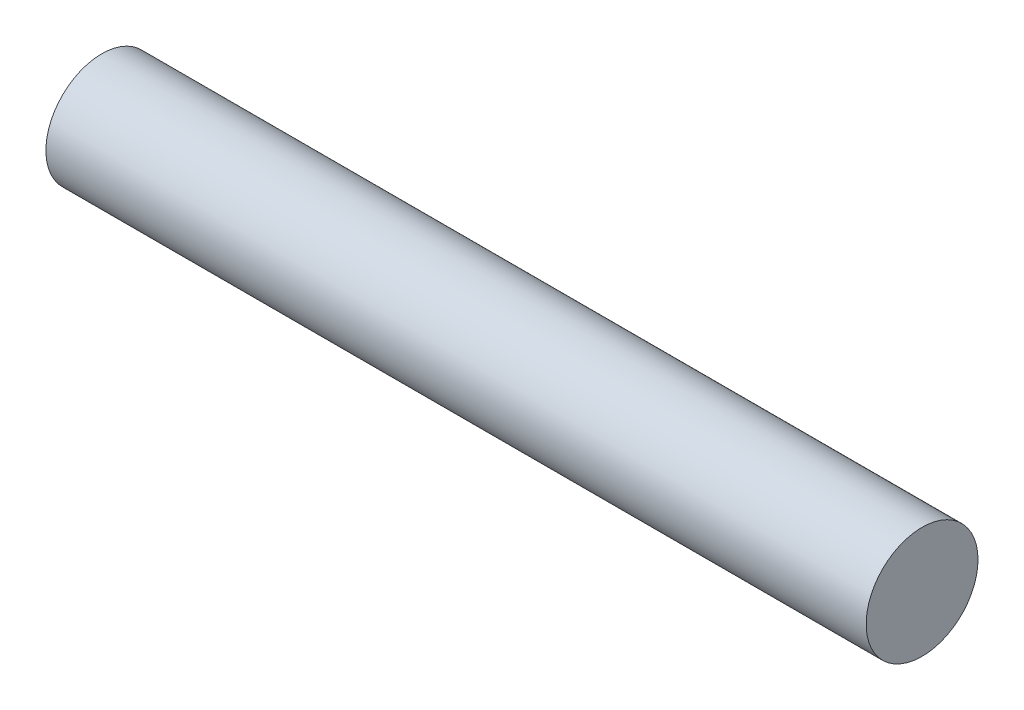
from build123d import *

# Parameters (mm, degrees)
SKETCH1_R           = 1.5
BOSS_EXTRUDE1_DEPTH = 22


with BuildPart() as part:
    # Sketch1 → Boss-Extrude1 (new body)
    with BuildSketch(Plane(origin=(0, 0, 0), x_dir=(0, 0, -1), z_dir=(1, 0, 0))):
        Circle(SKETCH1_R)
    extrude(amount=BOSS_EXTRUDE1_DEPTH)


solid = part.part
